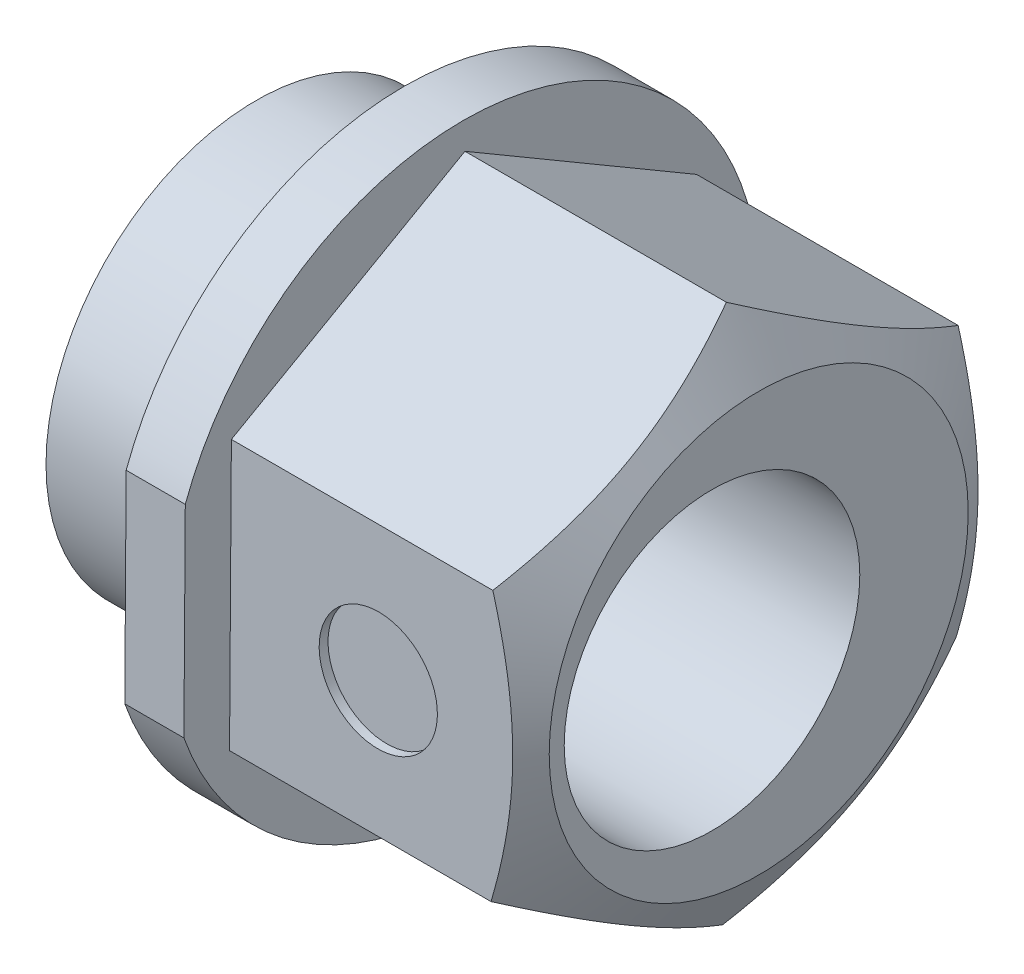
from build123d import *

# Parameters (mm, degrees)
BOSS_EXTRUDE1_DEPTH = 5
BOSS_EXTRUDE3_DEPTH = 1
SKETCH4_R           = 3.555
BOSS_EXTRUDE4_DEPTH = 2.5
SKETCH5_R           = 1
CUT_EXTRUDE3_DEPTH  = 0.15
SKETCH3_R           = 2.5
CUT_EXTRUDE5_DEPTH  = 9.5


with BuildPart() as part:
    # Sketch2 → Boss-Extrude1 (new body)
    with BuildSketch(Plane(origin=(0, 0, 0), x_dir=(0, 0, -1), z_dir=(1, 0, 0))):
        Polygon((3.919437566, -2.29861752), (3.950379949, 2.245023741), (0.030942383, 4.54364126), (-3.919437566, 2.29861752), (-3.950379949, -2.245023741), (-0.030942383, -4.54364126), align=None)
    extrude(amount=BOSS_EXTRUDE1_DEPTH)

    # Sketch6 → Boss-Extrude3 (add)
    with BuildSketch(Plane.ZY):
        with BuildLine():
            Line((4.699218, 1.737080939), (4.71082912, 0.032080939))
            Line((4.71082912, 0.032080939), (4.722440239, -1.672919061))
            ThreePointArc((4.722440239, -1.672919061), (-5.009883831, -0.034117514), (4.699218, 1.737080939))
        make_face()
    extrude(amount=BOSS_EXTRUDE3_DEPTH)

    # Sketch4 → Boss-Extrude4 (add)
    with BuildSketch(Plane.ZY.offset(1)):
        Circle(SKETCH4_R)
    extrude(amount=BOSS_EXTRUDE4_DEPTH)

    # Sketch5 → Cut-Extrude3 (cut)
    with BuildSketch(Plane(origin=(0, 0.02679689, 3.934908757), x_dir=(1, 0, 0), z_dir=(0, -0.006809883, -0.999976812))):
        with Locations((2.5, 0)):
            Circle(SKETCH5_R)
    extrude(amount=CUT_EXTRUDE3_DEPTH, mode=Mode.SUBTRACT)

    # Sketch3 → Cut-Extrude5 (cut, through all)
    with BuildSketch(Plane.ZY.offset(3.5)):
        with Locations((0.79, 0)):
            Circle(SKETCH3_R)
    extrude(amount=-CUT_EXTRUDE5_DEPTH, mode=Mode.SUBTRACT)

    # Sketch7 → Cut-Revolve1 (revolve, cut)
    with BuildSketch(Plane.XY):
        Polygon((4.422649731, 4.54364126), (5, 3.54364126), (9.422649731, 3.54364126), (9.422649731, 8.54364126), (4.422649731, 8.54364126), align=None)
    revolve(axis=Axis((0, 0, 0), (1, 0, 0)), mode=Mode.SUBTRACT)


solid = part.part
